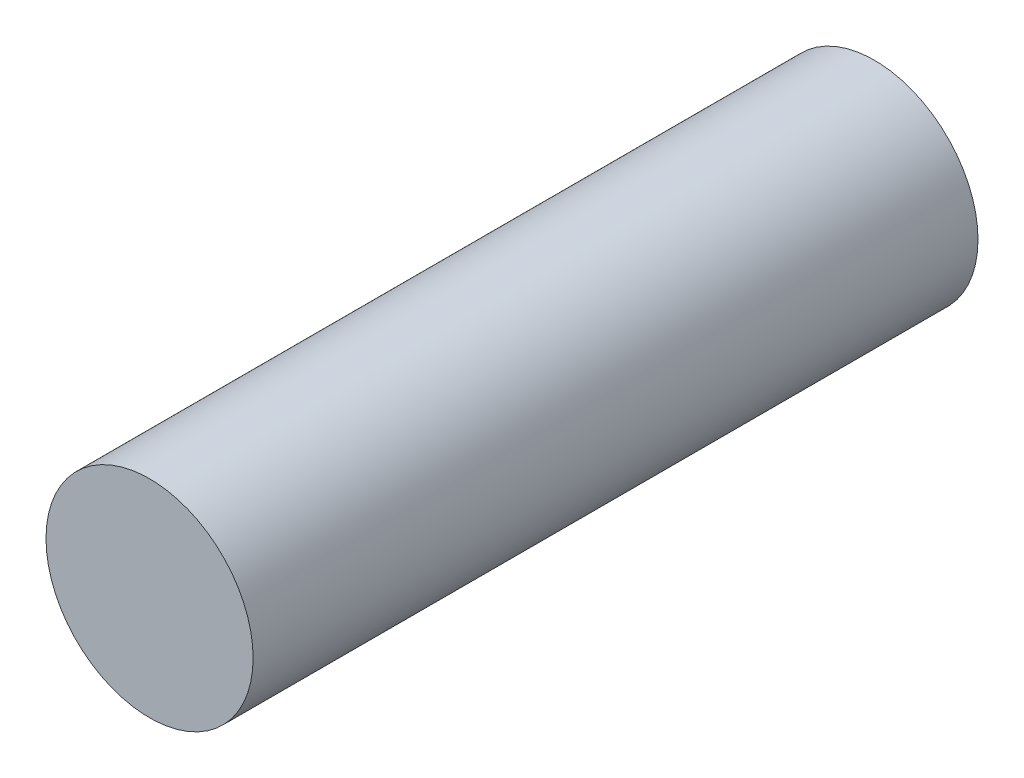
from build123d import *

# Parameters (mm, degrees)
SKETCH1_R           = 0.635
BOSS_EXTRUDE1_DEPTH = 4.445


with BuildPart() as part:
    # Sketch1 → Boss-Extrude1 (new body)
    with BuildSketch(Plane.XY):
        with Locations((0, 0.231823496)):
            Circle(SKETCH1_R)
    extrude(amount=BOSS_EXTRUDE1_DEPTH)


solid = part.part
